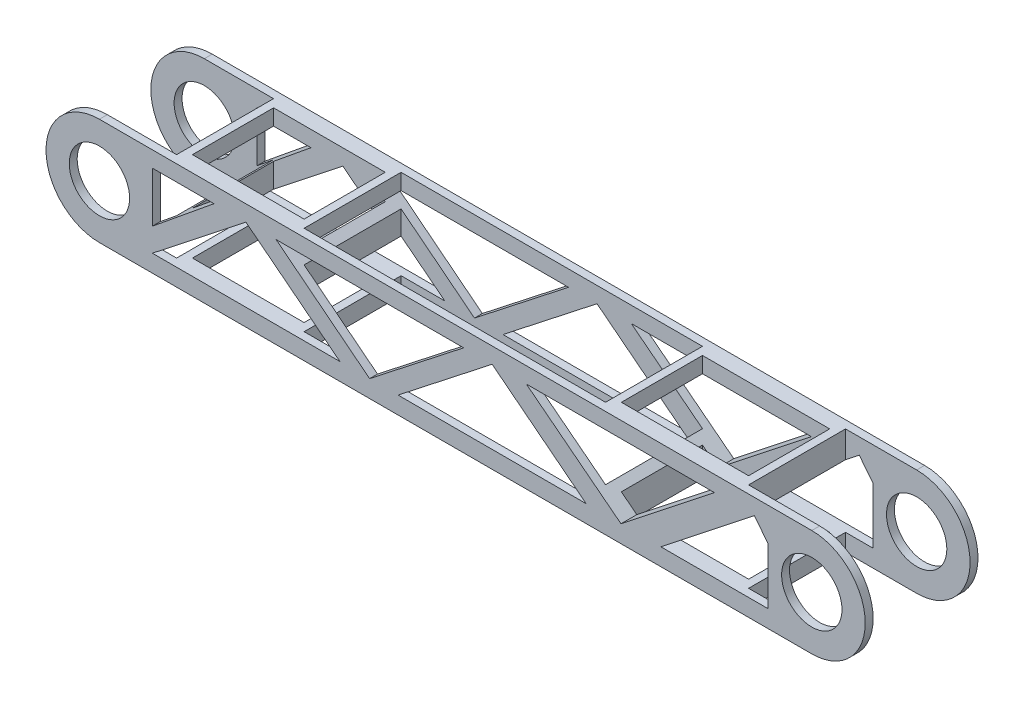
from build123d import *

# Parameters (mm, degrees)
CROQUIS1_R              = 15.25
SALIENTE_EXTRUIR1_DEPTH = 57
CROQUIS2_W              = 70
CROQUIS2_H              = 44
CROQUIS2_W_2            = 152.323993802
CORTAR_EXTRUIR1_DEPTH   = 40
CORTAR_EXTRUIR3_DEPTH   = 75
CROQUIS4_R              = 15.25
CORTAR_EXTRUIR4_DEPTH   = 2.5
CROQUIS5_R              = 15.25
CORTAR_EXTRUIR5_DEPTH   = 2.5
CROQUIS6_R              = 15.083558861
CORTAR_EXTRUIR6_DEPTH   = 2.5
CROQUIS7_R              = 15.25
CORTAR_EXTRUIR7_DEPTH   = 2.5
CROQUIS8_W              = 152.323993802
CROQUIS8_H              = 54
CORTAR_EXTRUIR8_DEPTH   = 2.5
CROQUIS9_W              = 152.323993802
CROQUIS9_H              = 54
CORTAR_EXTRUIR9_DEPTH   = 2.5
CROQUIS10_W             = 56.441876841
CROQUIS10_H             = 41
CORTAR_EXTRUIR10_DEPTH  = 70
CROQUIS11_W             = 64.296395464
CROQUIS11_H             = 41
CORTAR_EXTRUIR11_DEPTH  = 70
CORTAR_EXTRUIR12_DEPTH  = 78


with BuildPart() as part:
    # Croquis1 → Saliente-Extruir1 (new body)
    with BuildSketch(Plane.XY):
        with BuildLine():
            Line((-180, -35), (180, -35))
            ThreePointArc((180, -35), (215, 0), (180, 35))
            Line((180, 35), (-180, 35))
            ThreePointArc((-180, 35), (-215, 0), (-180, -35))
        make_face()
        with Locations((-180, 0)):
            Circle(CROQUIS1_R, mode=Mode.SUBTRACT)
        with Locations((180, 0)):
            Circle(CROQUIS1_R, mode=Mode.SUBTRACT)
    extrude(amount=SALIENTE_EXTRUIR1_DEPTH)

    # Croquis2 → Cortar-Extruir1 (cut, symmetric)
    with BuildSketch(Plane(origin=(0, 0, 0), x_dir=(1, 0, 0), z_dir=(0, 1, 0))):
        with Locations((-180, -28.5)):
            Rectangle(CROQUIS2_W, CROQUIS2_H)
        with Locations((179.062266107, -28.5)):
            Rectangle(CROQUIS2_W, CROQUIS2_H)
        with Locations((-4.396126258, -28.5)):
            Rectangle(CROQUIS2_W_2, CROQUIS2_H)
    extrude(amount=CORTAR_EXTRUIR1_DEPTH, both=True, mode=Mode.SUBTRACT)

    # Croquis3 → Cortar-Extruir3 (cut, symmetric)
    with BuildSketch(Plane.XY):
        with BuildLine():
            Line((-180, -35), (180, -35))
            ThreePointArc((180, -35), (215, 0), (180, 35))
            Line((180, 35), (-180, 35))
            ThreePointArc((-180, 35), (-215, 0), (-180, -35))
        make_face()
        with BuildLine():
            Line((-180, -27), (180, -27))
            ThreePointArc((180, -27), (207, 0), (180, 27))
            Line((180, 27), (-180, 27))
            ThreePointArc((-180, 27), (-207, 0), (-180, -27))
        make_face(mode=Mode.SUBTRACT)
    extrude(amount=CORTAR_EXTRUIR3_DEPTH, both=True, mode=Mode.SUBTRACT)

    # Croquis4 → Cortar-Extruir4 (cut)
    with BuildSketch(Plane.XY.offset(6.5)):
        with BuildLine():
            Line((-145, 27), (-180, 27))
            ThreePointArc((-180, 27), (-207, 0), (-180, -27))
            Line((-180, -27), (-145, -27))
            Line((-145, -27), (-145, 27))
        make_face()
        with Locations((-180, 0)):
            Circle(CROQUIS4_R, mode=Mode.SUBTRACT)
    extrude(amount=-CORTAR_EXTRUIR4_DEPTH, mode=Mode.SUBTRACT)

    # Croquis5 → Cortar-Extruir5 (cut)
    with BuildSketch(Plane(origin=(0, 0, 50.5), x_dir=(-1, 0, 0), z_dir=(0, 0, -1))):
        with BuildLine():
            Line((180, 27), (145, 27))
            Line((145, 27), (145, -27))
            Line((145, -27), (180, -27))
            ThreePointArc((180, -27), (207, 0), (180, 27))
        make_face()
        with Locations((180, 0)):
            Circle(CROQUIS5_R, mode=Mode.SUBTRACT)
    extrude(amount=-CORTAR_EXTRUIR5_DEPTH, mode=Mode.SUBTRACT)

    # Croquis6 → Cortar-Extruir6 (cut)
    with BuildSketch(Plane.XY.offset(6.5)):
        with BuildLine():
            Line((180, 27), (144.062266107, 27))
            Line((144.062266107, 27), (144.062266107, -27))
            Line((144.062266107, -27), (180, -27))
            ThreePointArc((180, -27), (207, 0), (180, 27))
        make_face()
        with Locations((180, 0)):
            Circle(CROQUIS6_R, mode=Mode.SUBTRACT)
    extrude(amount=-CORTAR_EXTRUIR6_DEPTH, mode=Mode.SUBTRACT)

    # Croquis7 → Cortar-Extruir7 (cut)
    with BuildSketch(Plane(origin=(0, 0, 50.5), x_dir=(-1, 0, 0), z_dir=(0, 0, -1))):
        with BuildLine():
            Line((-180, -27), (-144.062266107, -27))
            Line((-144.062266107, -27), (-144.062266107, 27))
            Line((-144.062266107, 27), (-180, 27))
            ThreePointArc((-180, 27), (-207, 0), (-180, -27))
        make_face()
        with Locations((-180, 0)):
            Circle(CROQUIS7_R, mode=Mode.SUBTRACT)
    extrude(amount=-CORTAR_EXTRUIR7_DEPTH, mode=Mode.SUBTRACT)

    # Croquis8 → Cortar-Extruir8 (cut)
    with BuildSketch(Plane(origin=(0, 0, 50.5), x_dir=(-1, 0, 0), z_dir=(0, 0, -1))):
        with Locations((4.396126258, 0)):
            Rectangle(CROQUIS8_W, CROQUIS8_H)
    extrude(amount=-CORTAR_EXTRUIR8_DEPTH, mode=Mode.SUBTRACT)

    # Croquis9 → Cortar-Extruir9 (cut)
    with BuildSketch(Plane.XY.offset(6.5)):
        with Locations((-4.396126258, 0)):
            Rectangle(CROQUIS9_W, CROQUIS9_H)
    extrude(amount=-CORTAR_EXTRUIR9_DEPTH, mode=Mode.SUBTRACT)

    # Croquis10 → Cortar-Extruir10 (cut)
    with BuildSketch(Plane(origin=(0, 27, 0), x_dir=(1, 0, 0), z_dir=(0, 1, 0))):
        with Locations((-112.779061579, -28.5)):
            Rectangle(CROQUIS10_W, CROQUIS10_H)
    extrude(amount=-CORTAR_EXTRUIR10_DEPTH, mode=Mode.SUBTRACT)

    # Croquis11 → Cortar-Extruir11 (cut)
    with BuildSketch(Plane(origin=(0, 27, 0), x_dir=(1, 0, 0), z_dir=(0, 1, 0))):
        with Locations((107.914068375, -28.5)):
            Rectangle(CROQUIS11_W, CROQUIS11_H)
    extrude(amount=-CORTAR_EXTRUIR11_DEPTH, mode=Mode.SUBTRACT)

    # Croquis12 → Cortar-Extruir12 (cut)
    with BuildSketch(Plane.XY.offset(57)):
        Polygon((-153.246746746, -18.260795107), (-105.980425778, 18.9839027), (-58.446911177, -18.260795107), align=None)
        Polygon((-153.246746746, 18.9839027), (-122.113012552, 18.9839027), (-153.246746746, -6.441367348), align=None)
        Polygon((157.831126984, 10.304103568), (157.831126984, -18.260795107), (103.74320228, -18.260795107), (150.988634974, 18.9839027), align=None)
        Polygon((-90.712084725, 18.9839027), (-43.46665203, -18.260795107), (4.066862571, 18.9839027), align=None)
        Polygon((-29.062556696, -18.260795107), (18.470957905, 18.9839027), (66.004472506, -18.260795107), align=None)
        Polygon((35.755872305, 18.9839027), (83.577468813, -18.260795107), (130.822901507, 18.9839027), align=None)
    extrude(amount=-CORTAR_EXTRUIR12_DEPTH, mode=Mode.SUBTRACT)


solid = part.part
